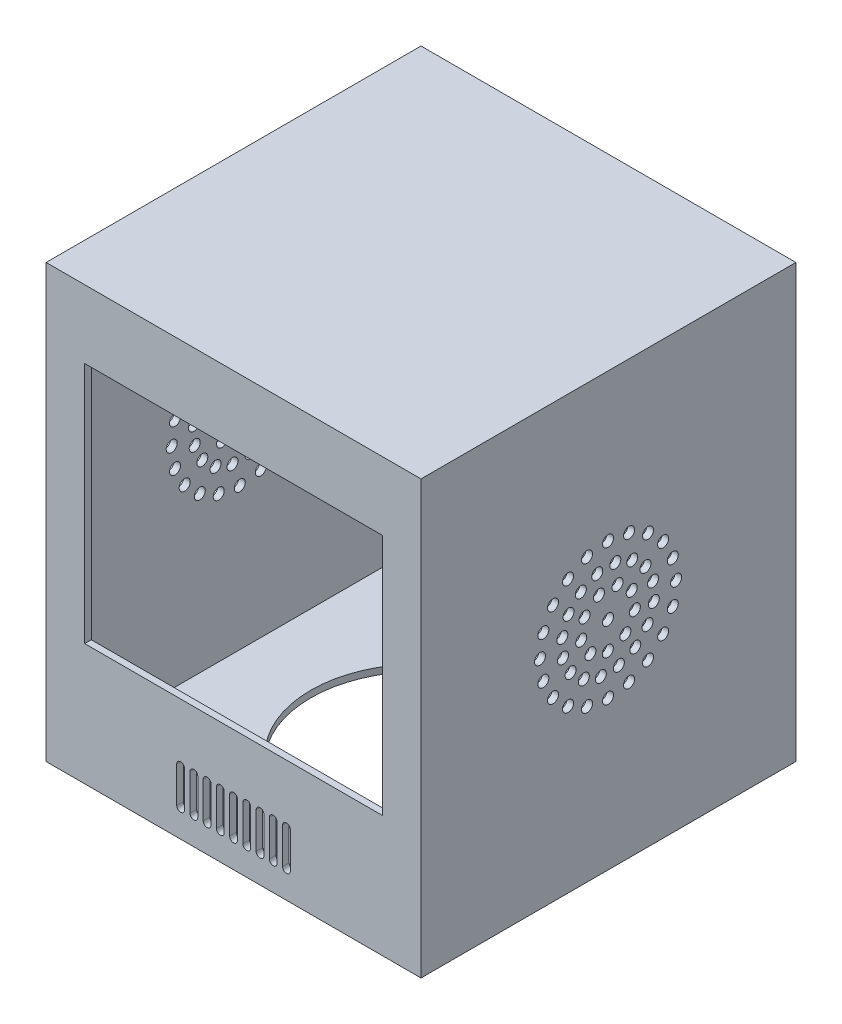
from build123d import *

# Parameters (mm, degrees)
SKETCH1_W           = 170
SKETCH1_H           = 170
SKETCH1_W_2         = 164
SKETCH1_H_2         = 164
BOSS_EXTRUDE1_DEPTH = 190
SKETCH2_W           = 135
SKETCH2_H           = 110
CUT_EXTRUDE2_DEPTH  = 19
SKETCH3_W           = 170
SKETCH3_H           = 170
BOSS_EXTRUDE3_DEPTH = 3
SKETCH4_W           = 170
SKETCH4_H           = 170
BOSS_EXTRUDE4_DEPTH = 3
SKETCH6_R           = 2.5
CUT_EXTRUDE3_DEPTH  = 171
CUT_EXTRUDE4_DEPTH  = 32
SKETCH9_R           = 50
CUT_EXTRUDE5_DEPTH  = 38


with BuildPart() as part:
    # Sketch1 → Boss-Extrude1 (new body)
    with BuildSketch(Plane(origin=(0, 0, 0), x_dir=(1, 0, 0), z_dir=(0, 1, 0))):
        Rectangle(SKETCH1_W, SKETCH1_H)
        Rectangle(SKETCH1_W_2, SKETCH1_H_2, mode=Mode.SUBTRACT)
    extrude(amount=BOSS_EXTRUDE1_DEPTH)

    # Sketch2 → Cut-Extrude2 (cut)
    with BuildSketch(Plane.XY.offset(85)):
        with Locations((0, 107.069890855)):
            Rectangle(SKETCH2_W, SKETCH2_H)
    extrude(amount=-CUT_EXTRUDE2_DEPTH, mode=Mode.SUBTRACT)

    # Sketch3 → Boss-Extrude3 (add)
    with BuildSketch(Plane.XZ):
        Rectangle(SKETCH3_W, SKETCH3_H)
    extrude(amount=BOSS_EXTRUDE3_DEPTH)

    # Sketch4 → Boss-Extrude4 (add)
    with BuildSketch(Plane(origin=(0, 190, 0), x_dir=(1, 0, 0), z_dir=(0, 1, 0))):
        Rectangle(SKETCH4_W, SKETCH4_H)
    extrude(amount=BOSS_EXTRUDE4_DEPTH)

    # Sketch6 → Cut-Extrude3 (cut, through all)
    with BuildSketch(Plane(origin=(85, 0, 0), x_dir=(0, 0, -1), z_dir=(1, 0, 0))):
        with Locations((-0.183103607, 95.366207215)):
            Circle(SKETCH6_R)
        with Locations((-0.183103607, 126.223231329)):
            Circle(SKETCH6_R)
        with Locations((9.35224124, 124.712981072)):
            Circle(SKETCH6_R)
        with Locations((17.954200097, 120.330064119)):
            Circle(SKETCH6_R)
        with Locations((24.780753297, 113.503510919)):
            Circle(SKETCH6_R)
        with Locations((29.16367025, 104.901552062)):
            Circle(SKETCH6_R)
        with Locations((30.673920507, 95.366207215)):
            Circle(SKETCH6_R)
        with Locations((29.16367025, 85.830862368)):
            Circle(SKETCH6_R)
        with Locations((24.780753297, 77.228903511)):
            Circle(SKETCH6_R)
        with Locations((17.954200097, 70.40235031)):
            Circle(SKETCH6_R)
        with Locations((9.35224124, 66.019433357)):
            Circle(SKETCH6_R)
        with Locations((-0.183103607, 64.5091831)):
            Circle(SKETCH6_R)
        with Locations((-9.718448455, 66.019433357)):
            Circle(SKETCH6_R)
        with Locations((-18.320407311, 70.40235031)):
            Circle(SKETCH6_R)
        with Locations((-25.146960512, 77.228903511)):
            Circle(SKETCH6_R)
        with Locations((-29.529877465, 85.830862368)):
            Circle(SKETCH6_R)
        with Locations((-31.040127722, 95.366207215)):
            Circle(SKETCH6_R)
        with Locations((-29.529877465, 104.901552062)):
            Circle(SKETCH6_R)
        with Locations((-25.146960512, 113.503510919)):
            Circle(SKETCH6_R)
        with Locations((-18.320407311, 120.330064119)):
            Circle(SKETCH6_R)
        with Locations((-9.718448455, 124.712981072)):
            Circle(SKETCH6_R)
        with Locations((3.102020158, 116.107662367)):
            Circle(SKETCH6_R)
        with Locations((10.789366252, 113.271650666)):
            Circle(SKETCH6_R)
        with Locations((16.806253274, 107.709697513)):
            Circle(SKETCH6_R)
        with Locations((20.236664721, 100.268559856)):
            Circle(SKETCH6_R)
        with Locations((20.558351545, 92.081083449)):
            Circle(SKETCH6_R)
        with Locations((17.722339844, 84.393737356)):
            Circle(SKETCH6_R)
        with Locations((12.160386691, 78.376850333)):
            Circle(SKETCH6_R)
        with Locations((4.719249034, 74.946438886)):
            Circle(SKETCH6_R)
        with Locations((-3.468227373, 74.624752062)):
            Circle(SKETCH6_R)
        with Locations((-11.155573466, 77.460763763)):
            Circle(SKETCH6_R)
        with Locations((-17.172460489, 83.022716917)):
            Circle(SKETCH6_R)
        with Locations((-20.602871936, 90.463854574)):
            Circle(SKETCH6_R)
        with Locations((-20.92455876, 98.651330981)):
            Circle(SKETCH6_R)
        with Locations((-18.088547059, 106.338677074)):
            Circle(SKETCH6_R)
        with Locations((-12.526593906, 112.355564097)):
            Circle(SKETCH6_R)
        with Locations((-5.085456248, 115.785975543)):
            Circle(SKETCH6_R)
        with Locations((4.136898309, 106.929050126)):
            Circle(SKETCH6_R)
        with Locations((10.558662011, 101.447015067)):
            Circle(SKETCH6_R)
        with Locations((11.954234198, 93.119702434)):
            Circle(SKETCH6_R)
        with Locations((7.670611135, 85.843554355)):
            Circle(SKETCH6_R)
        with Locations((-0.287852341, 83.023161381)):
            Circle(SKETCH6_R)
        with Locations((-8.19730272, 85.978216731)):
            Circle(SKETCH6_R)
        with Locations((-12.356820266, 93.326017164)):
            Circle(SKETCH6_R)
        with Locations((-10.820120492, 101.628445196)):
            Circle(SKETCH6_R)
        with Locations((-4.306242301, 107.000702479)):
            Circle(SKETCH6_R)
    extrude(amount=-CUT_EXTRUDE3_DEPTH, mode=Mode.SUBTRACT)

    # Sketch7 → Cut-Extrude4 (cut)
    with BuildSketch(Plane.XY.offset(85)):
        with BuildLine():
            Line((1.767099932, 25.648161373), (1.767099932, 9.351573112))
            ThreePointArc((1.767099932, 9.351573112), (0, 7.584473181), (-1.767099932, 9.351573112))
            Line((-1.767099932, 9.351573112), (-1.767099932, 25.648161373))
            ThreePointArc((-1.767099932, 25.648161373), (0, 27.415261305), (1.767099932, 25.648161373))
        make_face()
        with BuildLine():
            Line((7.767099932, 25.648161373), (7.767099932, 9.351573112))
            ThreePointArc((7.767099932, 9.351573112), (6, 7.584473181), (4.232900068, 9.351573112))
            Line((4.232900068, 9.351573112), (4.232900068, 25.648161373))
            ThreePointArc((4.232900068, 25.648161373), (6, 27.415261305), (7.767099932, 25.648161373))
        make_face()
        with BuildLine():
            Line((13.767099932, 25.648161373), (13.767099932, 9.351573112))
            ThreePointArc((13.767099932, 9.351573112), (12, 7.584473181), (10.232900068, 9.351573112))
            Line((10.232900068, 9.351573112), (10.232900068, 25.648161373))
            ThreePointArc((10.232900068, 25.648161373), (12, 27.415261305), (13.767099932, 25.648161373))
        make_face()
        with BuildLine():
            Line((19.767099932, 25.648161373), (19.767099932, 9.351573112))
            ThreePointArc((19.767099932, 9.351573112), (18, 7.584473181), (16.232900068, 9.351573112))
            Line((16.232900068, 9.351573112), (16.232900068, 25.648161373))
            ThreePointArc((16.232900068, 25.648161373), (18, 27.415261305), (19.767099932, 25.648161373))
        make_face()
        with BuildLine():
            Line((25.767099932, 25.648161373), (25.767099932, 9.351573112))
            ThreePointArc((25.767099932, 9.351573112), (24, 7.584473181), (22.232900068, 9.351573112))
            Line((22.232900068, 9.351573112), (22.232900068, 25.648161373))
            ThreePointArc((22.232900068, 25.648161373), (24, 27.415261305), (25.767099932, 25.648161373))
        make_face()
        with BuildLine():
            Line((-4.232900068, 25.648161373), (-4.232900068, 9.351573112))
            ThreePointArc((-4.232900068, 9.351573112), (-6, 7.584473181), (-7.767099932, 9.351573112))
            Line((-7.767099932, 9.351573112), (-7.767099932, 25.648161373))
            ThreePointArc((-7.767099932, 25.648161373), (-6, 27.415261305), (-4.232900068, 25.648161373))
        make_face()
        with BuildLine():
            Line((-10.232900068, 25.648161373), (-10.232900068, 9.351573112))
            ThreePointArc((-10.232900068, 9.351573112), (-12, 7.584473181), (-13.767099932, 9.351573112))
            Line((-13.767099932, 9.351573112), (-13.767099932, 25.648161373))
            ThreePointArc((-13.767099932, 25.648161373), (-12, 27.415261305), (-10.232900068, 25.648161373))
        make_face()
        with BuildLine():
            Line((-16.232900068, 25.648161373), (-16.232900068, 9.351573112))
            ThreePointArc((-16.232900068, 9.351573112), (-18, 7.584473181), (-19.767099932, 9.351573112))
            Line((-19.767099932, 9.351573112), (-19.767099932, 25.648161373))
            ThreePointArc((-19.767099932, 25.648161373), (-18, 27.415261305), (-16.232900068, 25.648161373))
        make_face()
        with BuildLine():
            Line((-22.232900068, 25.648161373), (-22.232900068, 9.351573112))
            ThreePointArc((-22.232900068, 9.351573112), (-24, 7.584473181), (-25.767099932, 9.351573112))
            Line((-25.767099932, 9.351573112), (-25.767099932, 25.648161373))
            ThreePointArc((-25.767099932, 25.648161373), (-24, 27.415261305), (-22.232900068, 25.648161373))
        make_face()
    extrude(amount=-CUT_EXTRUDE4_DEPTH, mode=Mode.SUBTRACT)

    # Sketch9 → Cut-Extrude5 (cut)
    with BuildSketch(Plane.XZ.offset(3)):
        Circle(SKETCH9_R)
    extrude(amount=-CUT_EXTRUDE5_DEPTH, mode=Mode.SUBTRACT)


solid = part.part
